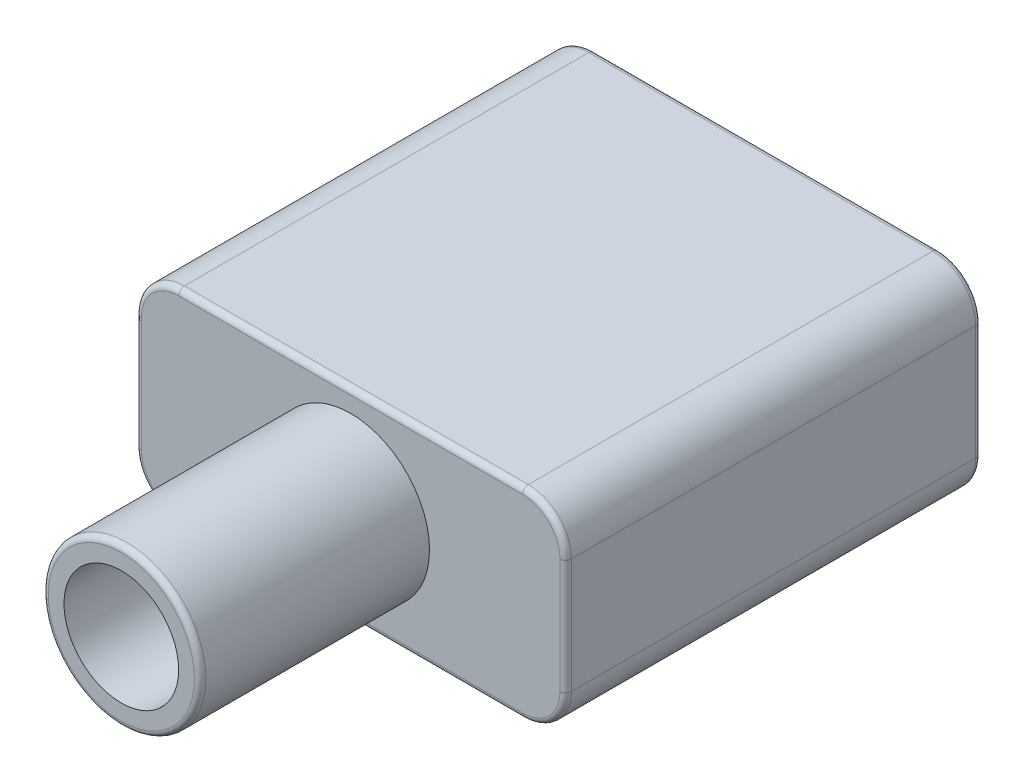
from build123d import *

# Parameters (mm, degrees)
SKETCH_1_R      = 2.75
SKETCH_1_R_2    = 2
EXTRUDE_1_DEPTH = 9
SKETCH_1_6_R    = 2.75
EXTRUDE_4_DEPTH = 1
SKETCH_1_7_W    = 12.2
SKETCH_1_7_H    = 4.7
EXTRUDE_5_DEPTH = 13.5
FILLET_1_R      = 0.2


with BuildPart() as part:
    # Sketch 1 → Extrude 1 (new body)
    with BuildSketch(Plane.XY):
        with Locations((7.5, 3.5)):
            Circle(SKETCH_1_R)
        with Locations((7.5, 3.5)):
            Circle(SKETCH_1_R_2, mode=Mode.SUBTRACT)
        with BuildLine():
            ThreePointArc((8.928285686, 5.85), (7.5, 6.25), (6.071714314, 5.85))
            Line((6.071714314, 5.85), (8.928285686, 5.85))
        make_face()
        with BuildLine():
            Line((8.928285686, 1.15), (6.071714314, 1.15))
            ThreePointArc((6.071714314, 1.15), (7.5, 0.75), (8.928285686, 1.15))
        make_face()
    extrude(amount=EXTRUDE_1_DEPTH)

    # Sketch 1_6 → Extrude 4 (add)
    with BuildSketch(Plane.XY):
        with BuildLine():
            ThreePointArc((0, 1.5), (0.439339828, 0.439339828), (1.5, 0))
            Line((1.5, 0), (13.5, 0))
            ThreePointArc((13.5, 0), (14.560660172, 0.439339828), (15, 1.5))
            Line((15, 1.5), (15, 5.5))
            ThreePointArc((15, 5.5), (14.560660172, 6.560660172), (13.5, 7))
            Line((13.5, 7), (1.5, 7))
            ThreePointArc((1.5, 7), (0.439339828, 6.560660172), (0, 5.5))
            Line((0, 5.5), (0, 1.5))
        make_face()
        with Locations((7.5, 3.5)):
            Circle(SKETCH_1_6_R, mode=Mode.SUBTRACT)
    extrude(amount=EXTRUDE_4_DEPTH)

    # Sketch 1_7 → Extrude 5 (add)
    with BuildSketch(Plane.XY):
        with BuildLine():
            ThreePointArc((0, 5.5), (0.439339828, 6.560660172), (1.5, 7))
            Line((1.5, 7), (13.5, 7))
            ThreePointArc((13.5, 7), (14.560660172, 6.560660172), (15, 5.5))
            Line((15, 5.5), (15, 1.5))
            ThreePointArc((15, 1.5), (14.560660172, 0.439339828), (13.5, 0))
            Line((13.5, 0), (1.5, 0))
            ThreePointArc((1.5, 0), (0.439339828, 0.439339828), (0, 1.5))
            Line((0, 1.5), (0, 5.5))
        make_face()
        with Locations((7.5, 3.5)):
            Rectangle(SKETCH_1_7_W, SKETCH_1_7_H, mode=Mode.SUBTRACT)
        with BuildLine():
            ThreePointArc((8.928285686, 5.85), (7.5, 6.25), (6.071714314, 5.85))
            Line((6.071714314, 5.85), (8.928285686, 5.85))
        make_face()
        with BuildLine():
            Line((8.928285686, 1.15), (6.071714314, 1.15))
            ThreePointArc((6.071714314, 1.15), (7.5, 0.75), (8.928285686, 1.15))
        make_face()
    extrude(amount=-EXTRUDE_5_DEPTH)

    # Fillet 1
    fillet_1_edges = [part.edges().sort_by_distance(p)[0] for p in [
        (0.439339828, 6.560660172, 1),
        (0, 3.5, 1),
        (0.439339828, 0.439339828, 1),
        (14.560660172, 6.560660172, 1),
        (7.5, 7, 1),
        (7.5, 0, 1),
        (14.560660172, 0.439339828, 1),
        (15, 3.5, 1),
        (15, 3.5, -13.5),
        (14.560660172, 0.439339828, -13.5),
        (7.5, 0, -13.5),
        (0.439339828, 6.560660172, -13.5),
        (7.5, 7, -13.5),
        (14.560660172, 6.560660172, -13.5),
        (0.439339828, 0.439339828, -13.5),
        (0, 3.5, -13.5),
        (9.896902755, 2.151906093, 9),
    ]]
    fillet(fillet_1_edges, radius=FILLET_1_R)


solid = part.part
